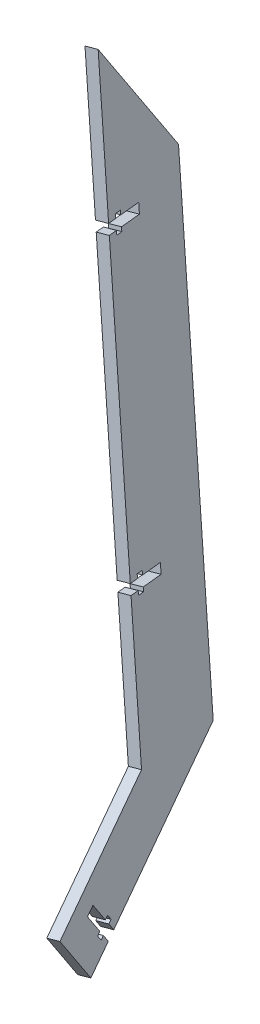
from build123d import *

# Parameters (mm, degrees)
BOSS_EXTRUDE1_DEPTH = 5
CUT_EXTRUDE2_DEPTH  = 714.328929729


with BuildPart() as part:
    # Sketch1 → Boss-Extrude1 (new body)
    with BuildSketch(Plane(origin=(-68.393987025, -9.003975274, 13.699403605), x_dir=(0.23308919144115517, -0.5341135383088325, 0.8126451605888809), z_dir=(0.972455360843524, 0.1280224242624249, -0.19478406005796045))):
        Polygon((290.734459145, 269.471566891), (290.734459145, 334.44233671), (415.531866377, 494.175733816), (509.260454317, 494.175733816), (509.260454317, 469.175733816), (446.760454317, 469.175733816), align=None)
    extrude(amount=BOSS_EXTRUDE1_DEPTH)

    # Sketch3 → Cut-Extrude2 (cut, through all)
    with BuildSketch(Plane(origin=(-63.53171022, -8.363863152, 12.725483305), x_dir=(-0.193117751863984, -0.025423689104136546, -0.9808461499885377), z_dir=(0.9724553608435241, 0.1280224242624253, -0.19478406005796034))):
        Polygon((-103.20824521, -577.778495346), (-102.919185311, -573.588454251), (-98.928669982, -573.863749393), (-98.811669547, -572.167780379), (-96.018308817, -572.360486979), (-96.135309253, -574.056455993), (-86.159020932, -574.74469385), (-86.448080832, -578.934734944), (-96.424369152, -578.246497088), (-96.541369588, -579.942466102), (-99.334730318, -579.749759503), (-99.217729882, -578.053790488), align=None)
        Polygon((-94.487300279, -451.364843062), (-94.19824038, -447.174801967), (-90.207725052, -447.45009711), (-90.090724616, -445.754128095), (-87.297363886, -445.946834695), (-87.414364322, -447.64280371), (-77.438076001, -448.331041566), (-77.727135901, -452.521082661), (-87.703424221, -451.832844804), (-87.820424657, -453.528813819), (-90.613785387, -453.336107219), (-90.496784951, -451.640138205), align=None)
        Polygon((-130.671777813, -684.777132582), (-134.151538298, -687.128997155), (-136.39140932, -683.81493955), (-137.799883802, -684.766884734), (-139.367793517, -682.447044411), (-137.959319035, -681.495099227), (-143.558996589, -673.209955215), (-140.079236104, -670.858090643), (-134.47955855, -679.143234654), (-133.071084068, -678.19128947), (-131.503174353, -680.511129793), (-132.911648835, -681.463074978), align=None)
    extrude(amount=-CUT_EXTRUDE2_DEPTH, mode=Mode.SUBTRACT)


solid = part.part
